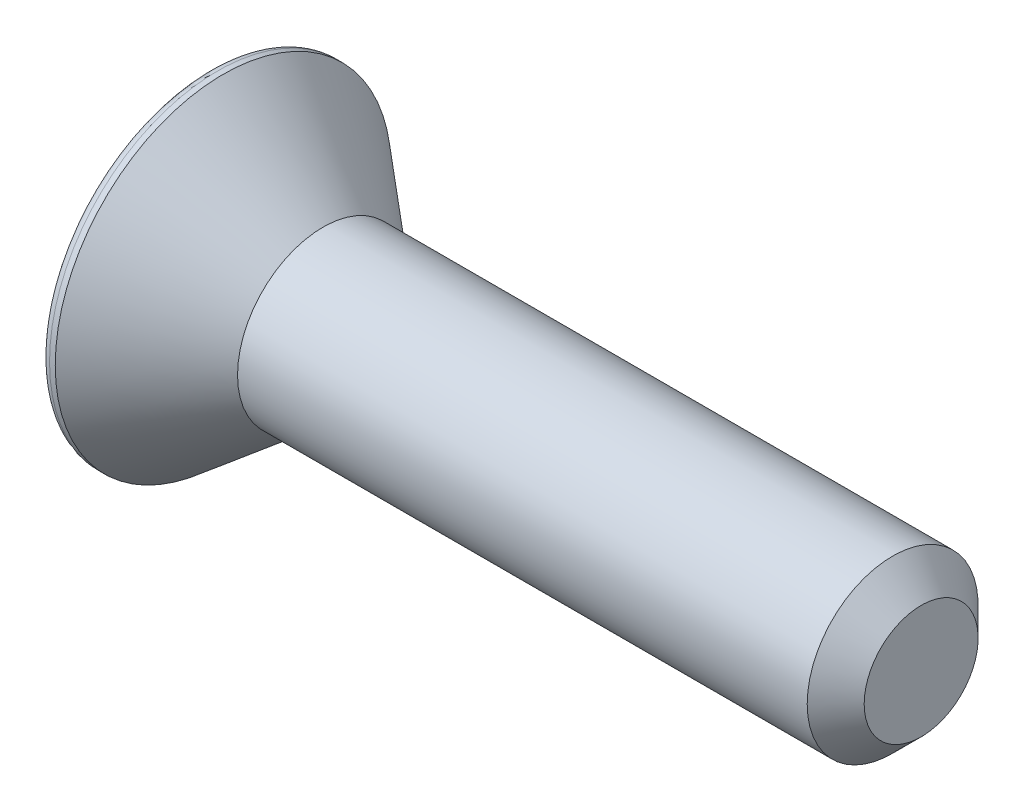
from build123d import *

# Parameters (mm, degrees)
CUT_EXTRUDE_1_DEPTH = 3
FILLET_1_R          = 0.3
CHAMFER_1_SIZE      = 1


with BuildPart() as part:
    # Эскиз1 → Повернуть1 (revolve)
    with BuildSketch(Plane.XY, mode=Mode.PRIVATE) as revolve_1_sk:
        Polygon((0, 0), (0, 5.9), (0.5, 5.9), (4, 3), (25, 3), (25, 0), align=None)
    revolve(revolve_1_sk.sketch.rotate(Axis((0, 0, 0), (1, 0, 0)), 90), axis=Axis((0, 0, 0), (1, 0, 0)))  # turned: the seam where the file's is

    # Эскиз2 → Вырез-Вытянуть1 (cut)
    with BuildSketch(Plane.ZY):
        Polygon((1.154700538, 2), (-1.154700538, 2), (-2.309401077, 0), (-1.154700538, -2), (1.154700538, -2), (2.309401077, 0), align=None)
    extrude(amount=-CUT_EXTRUDE_1_DEPTH, mode=Mode.SUBTRACT)

    # Скругление1
    fillet_1_edges = [part.edges().sort_by_distance(p)[0] for p in [
        (0, 0, -5.9),
    ]]
    fillet(fillet_1_edges, radius=FILLET_1_R)

    # Фаска1
    chamfer_1_edges = [part.edges().sort_by_distance(p)[0] for p in [
        (25, 0, -3),
    ]]
    chamfer(chamfer_1_edges, length=CHAMFER_1_SIZE)


solid = part.part
